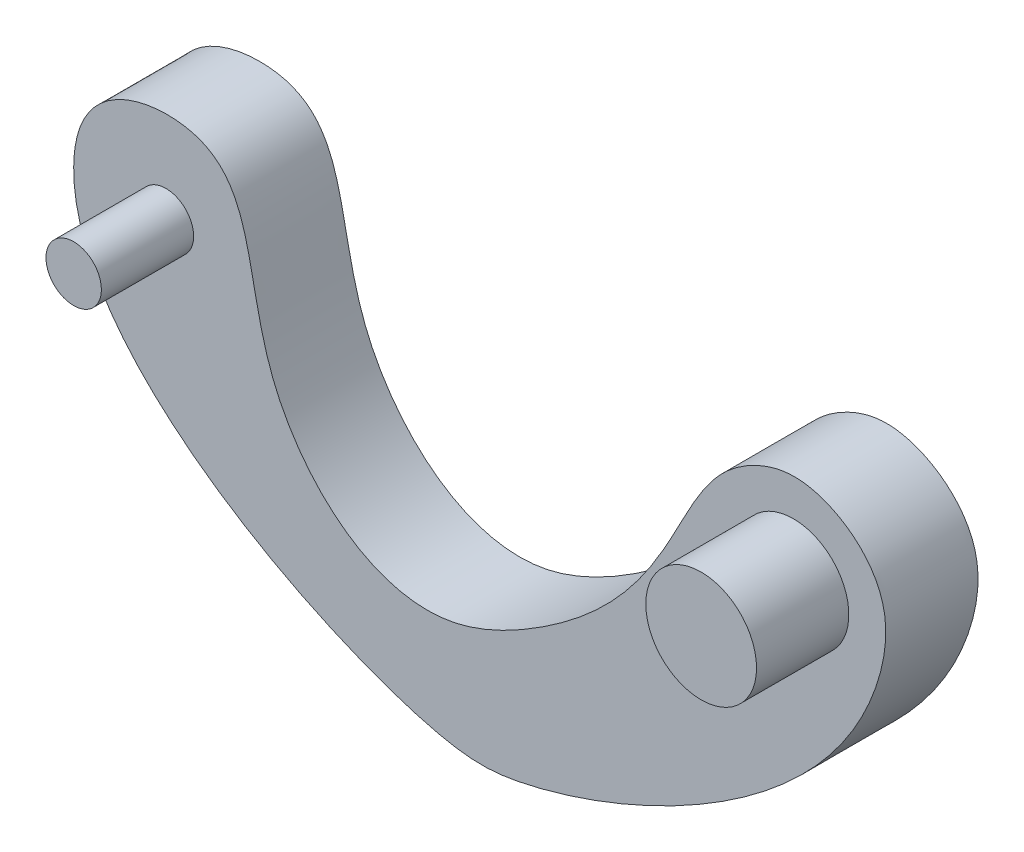
from build123d import *

# Parameters (mm, degrees)
SALIENTE_EXTRUIR4_DEPTH = 2.5
CROQUIS4_R              = 1.5
CROQUIS4_R_2            = 0.75
SALIENTE_EXTRUIR6_DEPTH = 2.5
CROQUIS5_R              = 0.75
CORTAR_EXTRUIR1_DEPTH   = 2


with BuildPart() as part:
    # Croquis1 → Saliente-Extruir4 (new body)
    with BuildSketch(Plane.XY):
        with BuildLine():
            add(Edge.make_bspline(
                [(-11, 0), (-11.048306131, -4.376050908), (-2.089434413, -8.693398442), (2.771230548, -8.349461193), (10.077141493, -5.05211068), (11.345069676, 1.282069838), (9.060644965, 2.780232127), (5.016478094, 1.571769184), (5.873962718, -2.299880995), (-1.706469618, -6.336121884), (-4.354365069, -4.663321085), (-6.467061292, -0.819337678), (-5.971697018, 2.356988298), (-9.373477772, 2.585336492), (-10.879010139, 1.752671035), (-10.998080157, 0.173918535), (-11, 0)],
                knots=[0, 0, 0, 0, 0.143873669, 0.181231095, 0.352202794, 0.38071078, 0.437802977, 0.471514382, 0.68411343, 0.72069081, 0.800710802, 0.823923962, 0.92960925, 0.94853792, 0.994281991, 1, 1, 1, 1], degree=3))
        make_face()
    extrude(amount=SALIENTE_EXTRUIR4_DEPTH)

    # Croquis4 → Saliente-Extruir6 (add)
    with BuildSketch(Plane.XY.offset(2.5)):
        with Locations((8.5, 0)):
            Circle(CROQUIS4_R)
        with Locations((-8.5, 0)):
            Circle(CROQUIS4_R_2)
    extrude(amount=SALIENTE_EXTRUIR6_DEPTH)

    # Croquis5 → Cortar-Extruir1 (cut)
    with BuildSketch(Plane(origin=(0, 0, 0), x_dir=(-1, 0, 0), z_dir=(0, 0, -1))):
        with Locations((-8.5, 0)):
            Circle(CROQUIS5_R)
    extrude(amount=-CORTAR_EXTRUIR1_DEPTH, mode=Mode.SUBTRACT)


solid = part.part
